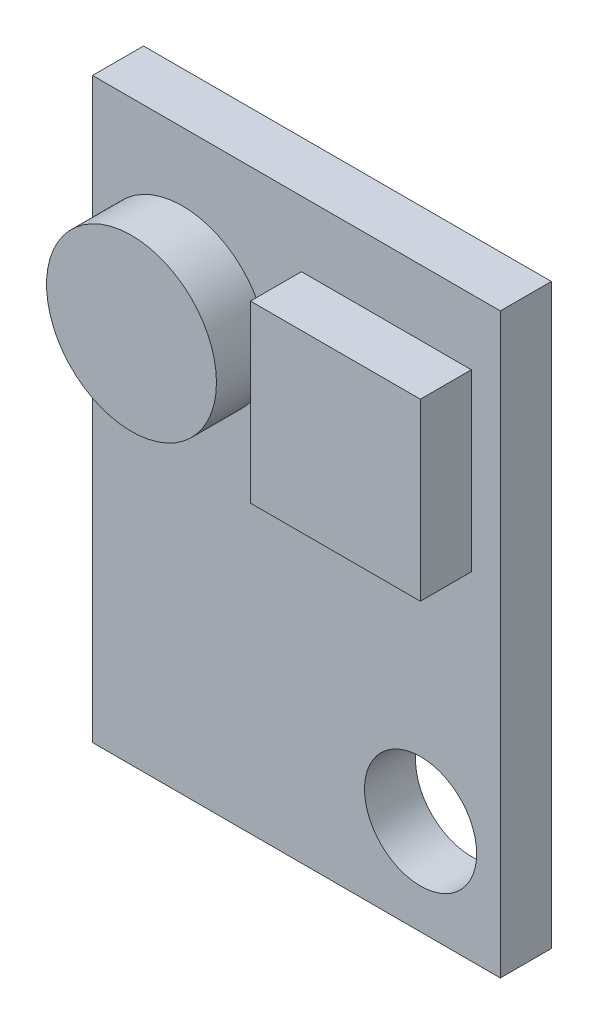
from build123d import *

# Parameters (mm, degrees)
ESBO_O1_W                = 12
ESBO_O1_H                = 17
ESBO_O1_R                = 1.65
RESSALTO_EXTRUS_O1_DEPTH = 1.5
ESBO_O2_R                = 2.5
ESBO_O2_W                = 5
ESBO_O2_H                = 5.148031572
RESSALTO_EXTRUS_O2_DEPTH = 1.5


with BuildPart() as part:
    # Esboço1 → Ressalto-extrusão1 (new body)
    with BuildSketch(Plane.XY):
        Rectangle(ESBO_O1_W, ESBO_O1_H)
        with Locations((3.652764924, -5.682274929)):
            Circle(ESBO_O1_R, mode=Mode.SUBTRACT)
    extrude(amount=RESSALTO_EXTRUS_O1_DEPTH)

    # Esboço2 → Ressalto-extrusão2 (add)
    with BuildSketch(Plane.XY.offset(1.5)):
        with Locations((-3.353706204, 3.998787781)):
            Circle(ESBO_O2_R)
        with Locations((2.646293796, 3.998787781)):
            Rectangle(ESBO_O2_W, ESBO_O2_H)
    extrude(amount=RESSALTO_EXTRUS_O2_DEPTH)


solid = part.part
